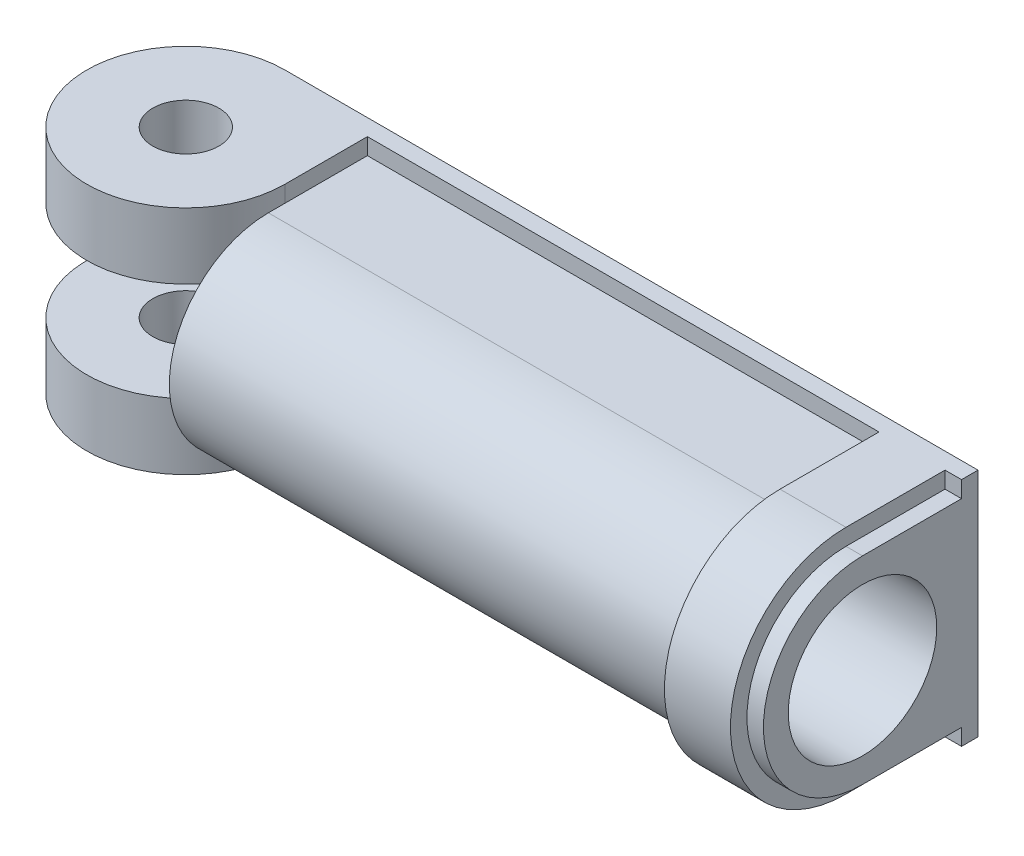
from build123d import *

# Parameters (mm, degrees)
BOSS_EXTRUDE1_DEPTH = 56.45658
BOSS_EXTRUDE2_DEPTH = 6.2738
BOSS_EXTRUDE3_DEPTH = 6.2738
SKETCH5_R           = 3.1369
CUT_EXTRUDE1_DEPTH  = 22.95576
SKETCH6_R           = 7.05612
CUT_EXTRUDE2_DEPTH  = 53.31968


with BuildPart() as part:
    # Sketch1 → Boss-Extrude1 (new body)
    with BuildSketch(Plane(origin=(0, 0, 0), x_dir=(0, 0, -1), z_dir=(1, 0, 0))):
        with BuildLine():
            Line((10.97788, 10.97788), (10.97788, -10.97788))
            Line((10.97788, -10.97788), (9.4107, -10.97788))
            Line((9.4107, -10.97788), (9.4107, -9.4107))
            Line((9.4107, -9.4107), (0, -9.4107))
            ThreePointArc((0, -9.4107), (-9.4107, 0), (0, 9.4107))
            Line((0, 9.4107), (9.4107, 9.4107))
            Line((9.4107, 9.4107), (9.4107, 10.97788))
            Line((9.4107, 10.97788), (10.97788, 10.97788))
        make_face()
    extrude(amount=-BOSS_EXTRUDE1_DEPTH)

    # Sketch3 → Boss-Extrude2 (add)
    with BuildSketch(Plane(origin=(-1.56718, 0, 0), x_dir=(0, 0, -1), z_dir=(1, 0, 0))):
        with BuildLine():
            Line((9.4107, 10.97788), (0, 10.97788))
            ThreePointArc((0, 10.97788), (-10.97788, 0), (0, -10.97788))
            Line((0, -10.97788), (9.4107, -10.97788))
            Line((9.4107, -10.97788), (9.4107, 10.97788))
        make_face()
    extrude(amount=-BOSS_EXTRUDE2_DEPTH)

    # Sketch4 → Boss-Extrude3 (add)
    with BuildSketch(Plane(origin=(0, 10.97788, 0), x_dir=(1, 0, 0), z_dir=(0, 1, 0))):
        with BuildLine():
            Line((-56.45658, 10.97788), (-65.86728, 10.97788))
            ThreePointArc((-65.86728, 10.97788), (-72.521649786, -5.087189786), (-56.45658, 1.56718))
            Line((-56.45658, 1.56718), (-56.45658, 10.97788))
        make_face()
    boss_extrude3 = extrude(amount=-BOSS_EXTRUDE3_DEPTH)

    # Mirror1: Boss-Extrude3 across plane
    add(boss_extrude3.mirror(Plane.ZX))

    # Sketch5 → Cut-Extrude1 (cut, through all)
    with BuildSketch(Plane(origin=(0, 10.97788, 0), x_dir=(1, 0, 0), z_dir=(0, 1, 0))):
        with Locations((-65.86728, 1.56718)):
            Circle(SKETCH5_R)
    extrude(amount=-CUT_EXTRUDE1_DEPTH, mode=Mode.SUBTRACT)

    # Sketch6 → Cut-Extrude2 (cut)
    with BuildSketch(Plane(origin=(0, 0, 0), x_dir=(0, 0, -1), z_dir=(1, 0, 0))):
        Circle(SKETCH6_R)
    extrude(amount=-CUT_EXTRUDE2_DEPTH, mode=Mode.SUBTRACT)


solid = part.part
